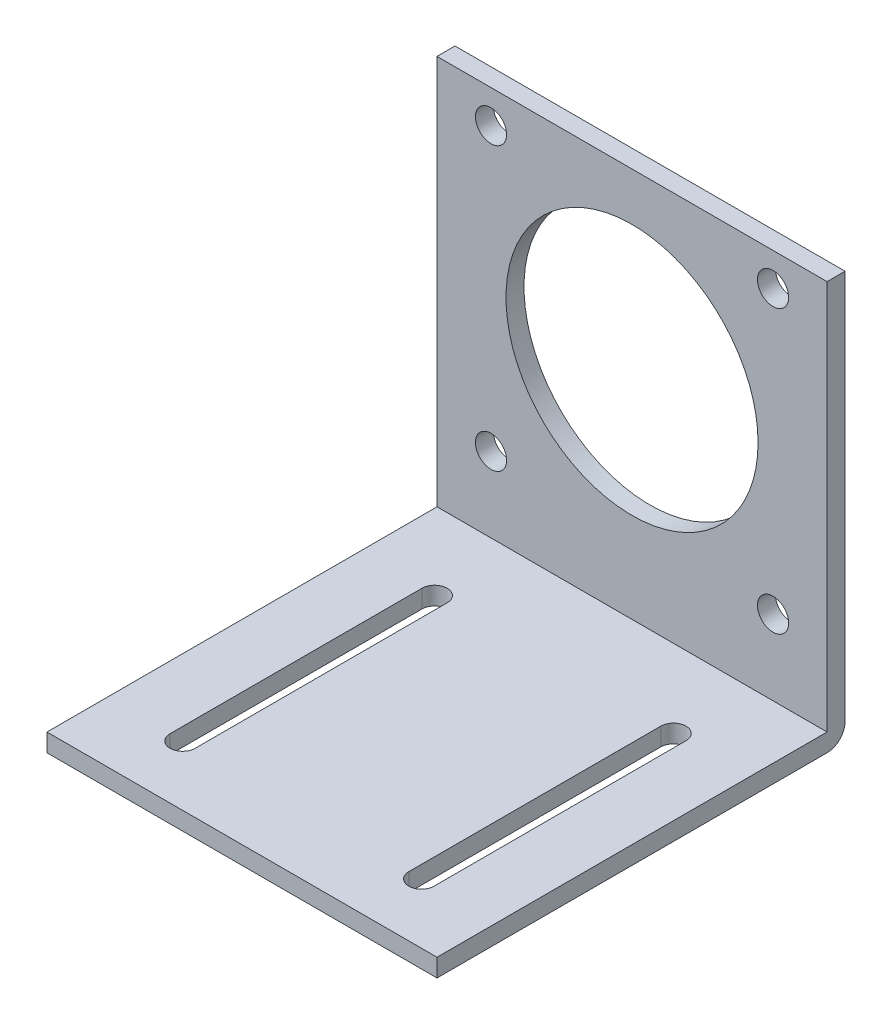
from build123d import *

# Parameters (mm, degrees)
SKETCH_1_W          = 65
SKETCH_1_H          = 68
SKETCH_1_R          = 21
SKETCH_1_R_2        = 2.6
EXTRUDE_1_DEPTH     = 3
SKETCH_2_W          = 65
SKETCH_2_H          = 3
EXTRUDE_2_DEPTH     = 65
CUT_EXTRUDE_1_DEPTH = 65
FILLET_1_R          = 3


with BuildPart() as part:
    # 草图1 → 凸台-拉伸1 (new body)
    with BuildSketch(Plane.XY):
        Rectangle(SKETCH_1_W, SKETCH_1_H)
        with Locations((0, 5)):
            Circle(SKETCH_1_R, mode=Mode.SUBTRACT)
        with Locations((23.5, 28.5)):
            Circle(SKETCH_1_R_2, mode=Mode.SUBTRACT)
        with Locations((-23.5, 28.5)):
            Circle(SKETCH_1_R_2, mode=Mode.SUBTRACT)
        with Locations((-23.5, -18.5)):
            Circle(SKETCH_1_R_2, mode=Mode.SUBTRACT)
        with Locations((23.5, -18.5)):
            Circle(SKETCH_1_R_2, mode=Mode.SUBTRACT)
    extrude(amount=EXTRUDE_1_DEPTH)

    # 草图2 → 凸台-拉伸2 (add)
    with BuildSketch(Plane.XY.offset(3)):
        with Locations((0, -32.5)):
            Rectangle(SKETCH_2_W, SKETCH_2_H)
    extrude(amount=EXTRUDE_2_DEPTH)

    # 草图3 → 切除-拉伸1 (cut)
    with BuildSketch(Plane(origin=(0, -31, 0), x_dir=(1, 0, 0), z_dir=(0, 1, 0))):
        with BuildLine():
            Line((22, -16), (22, -58))
            ThreePointArc((22, -58), (19.9, -60.1), (17.8, -58))
            Line((17.8, -58), (17.8, -16))
            ThreePointArc((17.8, -16), (19.9, -13.9), (22, -16))
        make_face()
        with BuildLine():
            Line((-22, -16), (-22, -58))
            ThreePointArc((-22, -58), (-19.9, -60.1), (-17.8, -58))
            Line((-17.8, -58), (-17.8, -16))
            ThreePointArc((-17.8, -16), (-19.9, -13.9), (-22, -16))
        make_face()
    extrude(amount=-CUT_EXTRUDE_1_DEPTH, mode=Mode.SUBTRACT)

    # 圆角1
    fillet_1_edges = [part.edges().sort_by_distance(p)[0] for p in [
        (0, -34, 0),
    ]]
    fillet(fillet_1_edges, radius=FILLET_1_R)


solid = part.part
